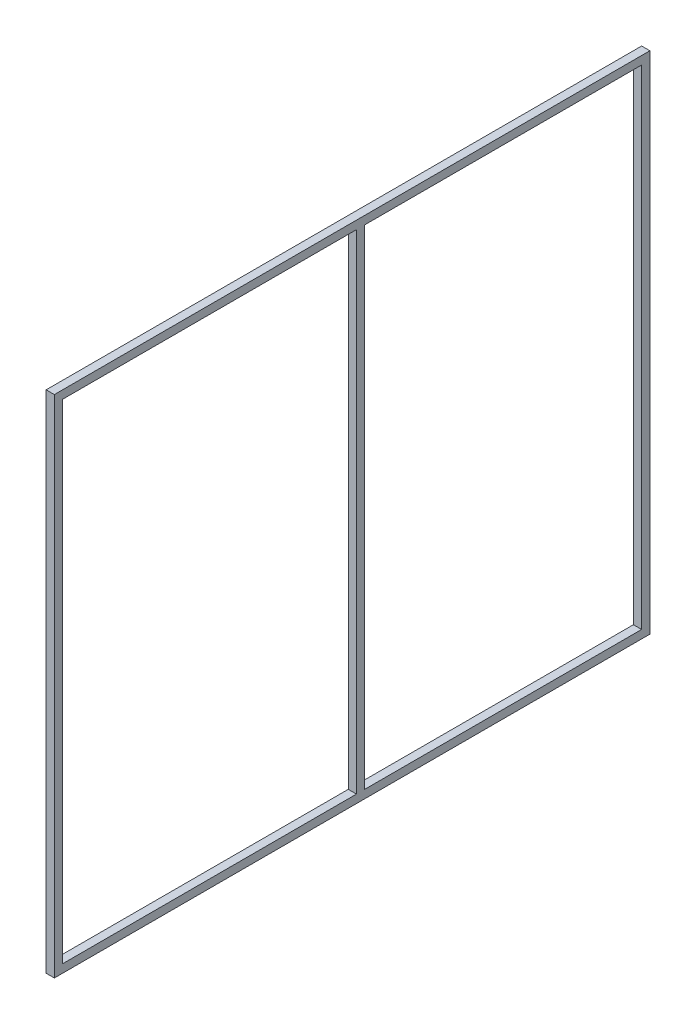
from build123d import *

# Parameters (mm, degrees)
SKETCH1_W           = 1118.25
SKETCH1_H           = 944.035
BOSS_EXTRUDE1_DEPTH = 15.875
BOSS_EXTRUDE3_REACH = 961.91
SKETCH3_W           = 15.875
SKETCH3_H           = 15.875


with BuildPart() as part:
    # Sketch1 → Boss-Extrude1 (new body)
    with BuildSketch(Plane(origin=(0, 0, 0), x_dir=(0, 0, -1), z_dir=(1, 0, 0))):
        Polygon((-575, -487.8925), (-575, 487.8925), (575, 487.8925), (575, -487.8925), (559.125, -487.8925), (-559.125, -487.8925), align=None)
        Rectangle(SKETCH1_W, SKETCH1_H, mode=Mode.SUBTRACT)
    extrude(amount=BOSS_EXTRUDE1_DEPTH)

    # Sketch3 → Boss-Extrude3 (add, up to next)
    with BuildSketch(Plane(origin=(0, -472.0175, 0), x_dir=(1, 0, 0), z_dir=(0, 1, 0)), mode=Mode.PRIVATE) as boss_extrude3_sk1:
        with Locations((7.9375, 16.375)):
            Rectangle(SKETCH3_W, SKETCH3_H)
    boss_extrude3_tool1 = extrude(boss_extrude3_sk1.sketch, amount=BOSS_EXTRUDE3_REACH, mode=Mode.PRIVATE) - part.part
    add(boss_extrude3_tool1.solids().sort_by_distance((7.9375, -472.0175, -16.375))[0])


solid = part.part
